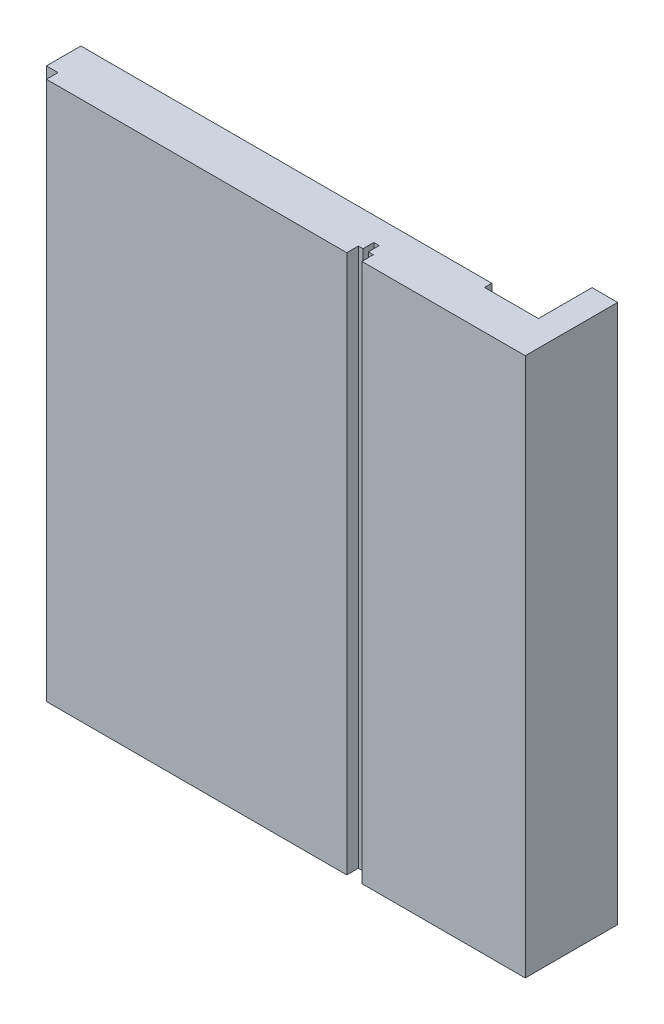
from build123d import *

# Parameters (mm, degrees)
BOSS_EXTRUDE1_DEPTH = 100


with BuildPart() as part:
    # Sketch1 → Boss-Extrude1 (new body)
    with BuildSketch(Plane(origin=(0, 0, 0), x_dir=(1, 0, 0), z_dir=(0, 1, 0))):
        Polygon((-4.75, 15), (-4.75, 5.05), (-14.75, 5.05), (-14.75, 6.4), (-91, 6.4), (-91, 0), (-88.85, 0), (-88.85, -2.14), (-33.12, -2.14), (-33.12, 0), (-32.25, 0), (-32.25, 2), (-31.25, 2), (-31.25, 0), (-30.32, 0), (-30.32, -2.14), (0, -2.14), (0, 0), (0, 15), align=None)
    extrude(amount=BOSS_EXTRUDE1_DEPTH)


solid = part.part
